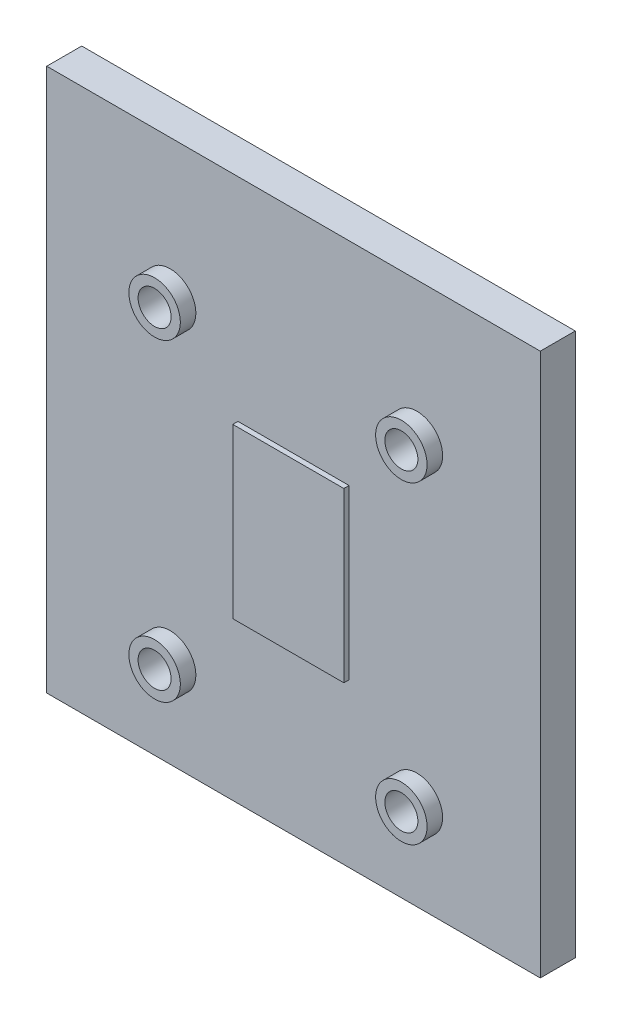
from build123d import *

# Parameters (mm, degrees)
SKETCH1_W                  = 50.8
SKETCH1_H                  = 55.88
BOSS_EXTRUDE1_DEPTH        = 3.6
SKETCH2_W                  = 11.43
SKETCH2_H                  = 17.3228
BOSS_EXTRUDE2_DEPTH        = 0.5332
SKETCH3_W                  = 2.648
SKETCH3_H                  = 1.6
SKETCH4_W                  = 2.648
SKETCH4_H                  = 1.6
SKETCH5_W                  = 2.648
SKETCH5_H                  = 1.6
SKETCH6_W                  = 2.648
SKETCH6_H                  = 1.6
F_3_4_3_4_DIAMETER_HOLE1_D = 3.4


with BuildPart() as part:
    # Sketch1 → Boss-Extrude1 (new body)
    with BuildSketch(Plane.XY):
        with Locations((0, 2.54)):
            Rectangle(SKETCH1_W, SKETCH1_H)
    extrude(amount=-BOSS_EXTRUDE1_DEPTH)

    # Sketch2 → Boss-Extrude2 (add)
    with BuildSketch(Plane.XY):
        Rectangle(SKETCH2_W, SKETCH2_H)
    extrude(amount=BOSS_EXTRUDE2_DEPTH)

    # Sketch3 → Revolve1 (revolve)
    with BuildSketch(Plane.XZ.offset(-16.129)):
        with Locations((-11.376, 0.8)):
            Rectangle(SKETCH3_W, SKETCH3_H)
    revolve(axis=Axis((-12.7, 16.129, 1.6), (0, 0, -1)))

    # Sketch4 → Revolve2 (revolve)
    with BuildSketch(Plane.XZ.offset(16.129)):
        with Locations((-11.376, 0.8)):
            Rectangle(SKETCH4_W, SKETCH4_H)
    revolve(axis=Axis((-12.7, -16.129, 1.6), (0, 0, -1)))

    # Sketch5 → Revolve3 (revolve)
    with BuildSketch(Plane.XZ.offset(16.129)):
        with Locations((14.024, 0.8)):
            Rectangle(SKETCH5_W, SKETCH5_H)
    revolve(axis=Axis((12.7, -16.129, 1.6), (0, 0, -1)))

    # Sketch6 → Revolve4 (revolve)
    with BuildSketch(Plane.XZ.offset(-16.129)):
        with Locations((14.024, 0.8)):
            Rectangle(SKETCH6_W, SKETCH6_H)
    revolve(axis=Axis((12.7, 16.129, 1.6), (0, 0, -1)))

    # Ø3.4 (3.4) Diameter Hole1 (through all)
    with Locations(Plane.XY.offset(1.6)):
        with Locations((-12.7, -16.129), (12.7, -16.129), (12.7, 16.129), (-12.7, 16.129)):
            Hole(F_3_4_3_4_DIAMETER_HOLE1_D / 2)


solid = part.part
